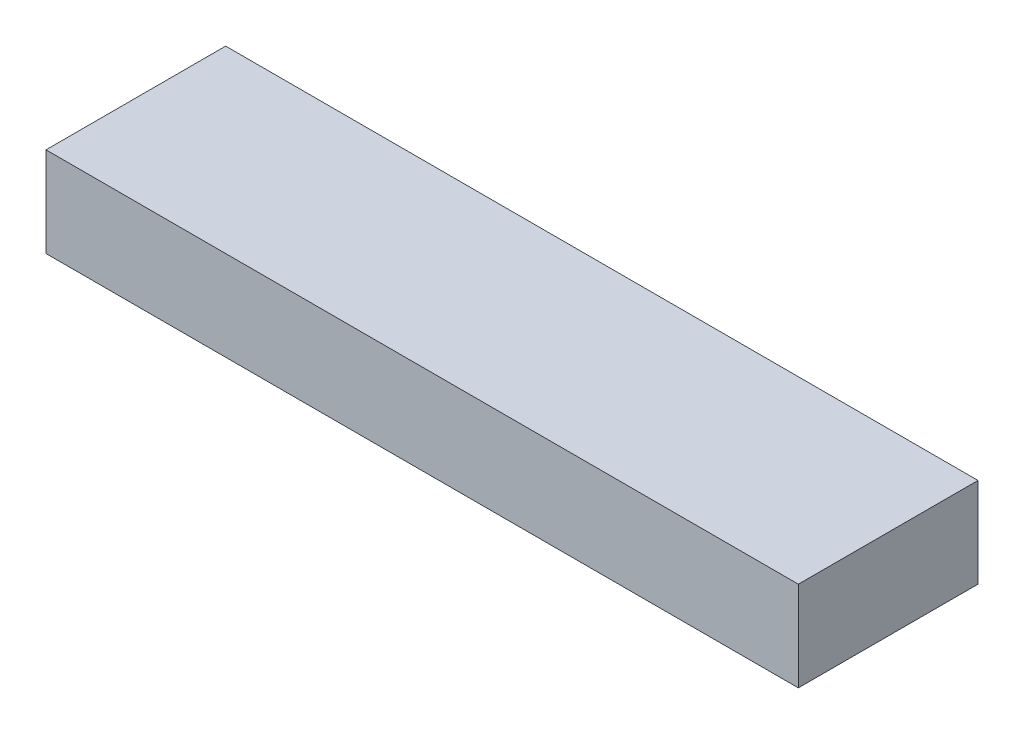
from build123d import *

# Parameters (mm, degrees)
SKETCH1_W           = 425.45
SKETCH1_H           = 101.6
BOSS_EXTRUDE1_DEPTH = 25.4


with BuildPart() as part:
    # Sketch1 → Boss-Extrude1 (new body, symmetric)
    with BuildSketch(Plane(origin=(0, 0, 0), x_dir=(1, 0, 0), z_dir=(0, 1, 0))):
        Rectangle(SKETCH1_W, SKETCH1_H)
    extrude(amount=BOSS_EXTRUDE1_DEPTH, both=True)


solid = part.part
